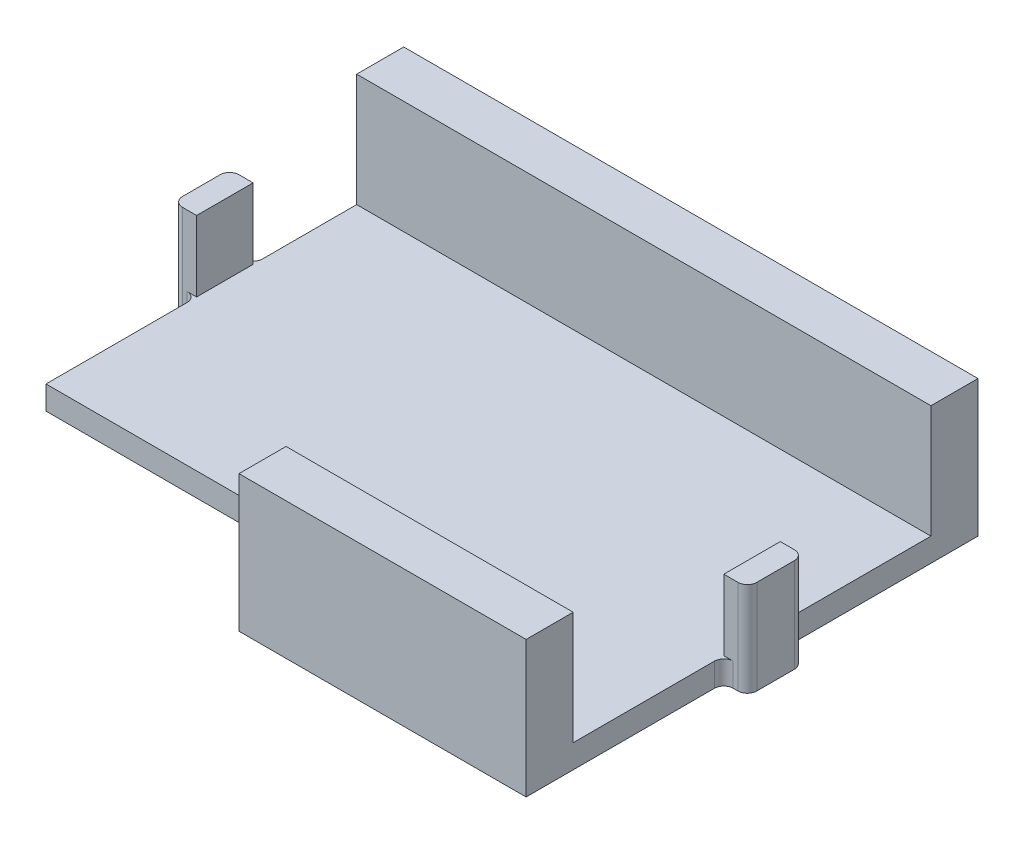
from build123d import *

# Parameters (mm, degrees)
BOSS_EXTRUDE1_DEPTH = 2.5
SKETCH2_W           = 61
SKETCH2_H           = 5
SKETCH2_W_2         = 30.5
BOSS_EXTRUDE2_DEPTH = 12
CUT_EXTRUDE1_DEPTH  = 1
SKETCH5_W           = 2.5
SKETCH5_H           = 6
BOSS_EXTRUDE3_DEPTH = 10
FILLET4_R           = 1


with BuildPart() as part:
    # Sketch1 → Boss-Extrude1 (new body)
    with BuildSketch(Plane(origin=(0, 0, 0), x_dir=(1, 0, 0), z_dir=(0, 1, 0))):
        Polygon((0, 10), (30.5, 10), (30.5, 0), (61, 0), (61, 48), (0, 48), align=None)
    extrude(amount=BOSS_EXTRUDE1_DEPTH)

    # Sketch2 → Boss-Extrude2 (add)
    with BuildSketch(Plane(origin=(0, 2.5, 0), x_dir=(1, 0, 0), z_dir=(0, 1, 0))):
        with Locations((30.5, 45.5)):
            Rectangle(SKETCH2_W, SKETCH2_H)
        with Locations((45.75, 2.5)):
            Rectangle(SKETCH2_W_2, SKETCH2_H)
    extrude(amount=BOSS_EXTRUDE2_DEPTH)

    # Sketch3 → Cut-Extrude1 (cut)
    with BuildSketch(Plane.XZ):
        with BuildLine():
            Line((38.1875, -27), (39.6, -27))
            Line((39.6, -27), (39.6, -24.8421875))
            add(Edge.make_bspline(
                [(39.6, -24.8421875), (39.602615405, -24.769084793), (39.607534256, -24.631598895), (39.645917421, -24.438286667), (39.71249642, -24.273057168), (39.80650625, -24.137413973), (39.920250057, -24.03091493), (40.049992557, -23.954750809), (40.194402262, -23.908778619), (40.294972194, -23.902988305), (40.346875, -23.9)],
                knots=[0, 0, 0, 0, 0.000219202, 0.000412257, 0.000588099, 0.000749771, 0.000903445, 0.001051907, 0.001197689, 0.001353164, 0.001353164, 0.001353164, 0.001353164], degree=3))
            add(Edge.make_bspline(
                [(40.346875, -23.9), (40.400811886, -23.903069829), (40.505370426, -23.9090208), (40.654616604, -23.95331831), (40.785818729, -24.030620386), (40.898267418, -24.137525593), (40.989912112, -24.272508914), (41.055867465, -24.436263579), (41.094160201, -24.627408298), (41.097981983, -24.763877569), (41.1, -24.8359375)],
                knots=[0, 0, 0, 0, 0.000161694, 0.00031345, 0.000461912, 0.000614446, 0.000775232, 0.000947589, 0.001140645, 0.001356632, 0.001356632, 0.001356632, 0.001356632], degree=3))
            Line((41.1, -24.8359375), (41.1, -30.7484375))
            add(Edge.make_bspline(
                [(41.1, -30.7484375), (41.099564666, -30.789608087), (41.098725346, -30.868984644), (41.087679787, -30.98393408), (41.069116088, -31.089395785), (41.044395541, -31.186415943), (41.011489006, -31.273687026), (40.972763577, -31.35292309), (40.925545184, -31.42249894), (40.851306001, -31.502978541), (40.733925262, -31.585343097), (40.562936526, -31.653276145), (40.358565351, -31.693106891), (40.211651668, -31.697592735), (40.1328125, -31.7)],
                knots=[0, 0, 0, 0, 0.000123477, 0.000238063, 0.000345954, 0.000444491, 0.000537941, 0.000625288, 0.000708497, 0.00078922, 0.000952693, 0.001133464, 0.001337549, 0.001573905, 0.001573905, 0.001573905, 0.001573905], degree=3))
            Line((40.1328125, -31.7), (38.1734375, -31.7))
            add(Edge.make_bspline(
                [(38.1734375, -31.7), (38.103112581, -31.700035372), (37.96658071, -31.700104044), (37.768157568, -31.691054163), (37.58205737, -31.681244136), (37.408685819, -31.664781958), (37.247289379, -31.647623515), (37.099076931, -31.62146964), (36.962560228, -31.594754723), (36.876957605, -31.570836449), (36.8359375, -31.559375)],
                knots=[0, 0, 0, 0, 0.000210943, 0.000409535, 0.000595793, 0.000769933, 0.000931959, 0.001082487, 0.001221304, 0.001349028, 0.001349028, 0.001349028, 0.001349028], degree=3))
            add(Edge.make_bspline(
                [(36.8359375, -31.559375), (36.758174787, -31.535693231), (36.605197894, -31.48910582), (36.390091341, -31.388381046), (36.189773634, -31.269615451), (36.006592335, -31.12861923), (35.842172885, -30.96773624), (35.699559897, -30.788048857), (35.576231309, -30.592456035), (35.474550885, -30.379737692), (35.397163841, -30.150698292), (35.341005355, -29.908428323), (35.305483612, -29.652613392), (35.301855407, -29.477202426), (35.3, -29.3875)],
                knots=[0, 0, 0, 0, 0.000243595, 0.000479206, 0.000710461, 0.000941103, 0.001170924, 0.00139884, 0.001627734, 0.001863257, 0.002104389, 0.002351501, 0.002608498, 0.002877471, 0.002877471, 0.002877471, 0.002877471], degree=3))
            add(Edge.make_bspline(
                [(35.3, -29.3875), (35.301809825, -29.292586825), (35.30533284, -29.107828413), (35.341011258, -28.839627251), (35.395696925, -28.588344436), (35.476429153, -28.355502686), (35.577363674, -28.139551849), (35.704023887, -27.942951805), (35.851833656, -27.762963601), (36.023207918, -27.601603438), (36.217200455, -27.458365944), (36.433788728, -27.334655233), (36.673512874, -27.232454742), (36.933425896, -27.145634461), (37.216328859, -27.081746386), (37.519917531, -27.032769881), (37.84636014, -27.005079255), (38.071303311, -27.001730061), (38.1875, -27)],
                knots=[0, 0, 0, 0, 0.000284585, 0.000553975, 0.000810225, 0.00105482, 0.001291754, 0.001523642, 0.001754511, 0.001988834, 0.002227902, 0.002476359, 0.002735282, 0.003008523, 0.003297327, 0.003604298, 0.003930513, 0.004279076, 0.004279076, 0.004279076, 0.004279076], degree=3))
        make_face()
        with BuildLine():
            Line((38.5609375, -30.5), (39.6, -30.5))
            Line((39.6, -30.5), (39.6, -28.2))
            Line((39.6, -28.2), (38.5609375, -28.2))
            add(Edge.make_bspline(
                [(38.5609375, -28.2), (38.473925807, -28.201685184), (38.306945409, -28.204919149), (38.067107498, -28.224188963), (37.84970512, -28.25980799), (37.65410835, -28.309033712), (37.480223381, -28.3740791), (37.327553707, -28.457520614), (37.19637362, -28.559225985), (37.088067853, -28.680511212), (37.001621577, -28.82004504), (36.943027083, -28.981175779), (36.906595982, -29.161394296), (36.902263617, -29.288352923), (36.9, -29.3546875)],
                knots=[0, 0, 0, 0, 0.000261054, 0.000500978, 0.000721119, 0.000921217, 0.001105194, 0.001276535, 0.001441259, 0.001600603, 0.001761927, 0.00193054, 0.002112254, 0.002311084, 0.002311084, 0.002311084, 0.002311084], degree=3))
            add(Edge.make_bspline(
                [(36.9, -29.3546875), (36.903364233, -29.434236925), (36.909848384, -29.587558781), (36.966431543, -29.805808259), (37.057238421, -30.003435042), (37.149400887, -30.111694511), (37.1953125, -30.165625)],
                knots=[0, 0, 0, 0, 0.000238239, 0.000459177, 0.000672331, 0.000883921, 0.000883921, 0.000883921, 0.000883921], degree=3))
            add(Edge.make_bspline(
                [(37.1953125, -30.165625), (37.225735979, -30.19276864), (37.290030891, -30.250132162), (37.408815453, -30.317269388), (37.54843091, -30.373136489), (37.708729079, -30.419369207), (37.890973375, -30.456831222), (38.095231339, -30.482248599), (38.321103054, -30.498011146), (38.47861699, -30.499317348), (38.5609375, -30.5)],
                knots=[0, 0, 0, 0, 0.000122035, 0.000257901, 0.000406462, 0.000572587, 0.000757676, 0.00096408, 0.001189621, 0.001436541, 0.001436541, 0.001436541, 0.001436541], degree=3))
        make_face(mode=Mode.SUBTRACT)
        with BuildLine():
            add(Edge.make_bspline(
                [(27.3953125, -26.4515625), (27.397434395, -26.389433762), (27.401815522, -26.261155035), (27.438676119, -26.066027702), (27.49508646, -25.862986158), (27.575462199, -25.654509555), (27.676999221, -25.441216064), (27.810927351, -25.232591398), (27.966003207, -25.022936194), (28.147847897, -24.817903952), (28.356369794, -24.622072842), (28.59422462, -24.445271264), (28.857924229, -24.287111598), (29.147826391, -24.149406865), (29.463719448, -24.035657986), (29.807343765, -23.957565551), (30.175103983, -23.907880656), (30.428998104, -23.902673778), (30.559375, -23.9)],
                knots=[0, 0, 0, 0, 0.000186259, 0.000384573, 0.000593838, 0.000817864, 0.001054066, 0.001301178, 0.001560242, 0.001835849, 0.002122179, 0.002416867, 0.002723153, 0.003043252, 0.003378327, 0.003728149, 0.004098518, 0.004489455, 0.004489455, 0.004489455, 0.004489455], degree=3))
            add(Edge.make_bspline(
                [(30.559375, -23.9), (30.658907566, -23.900818023), (30.853542013, -23.902417653), (31.138651795, -23.926098172), (31.410314201, -23.958436313), (31.668437928, -24.009492265), (31.91383369, -24.073164845), (32.148411511, -24.150895125), (32.370734316, -24.246731815), (32.582544659, -24.358413872), (32.786445998, -24.485270243), (32.979262764, -24.63299341), (33.165986579, -24.797359597), (33.279688705, -24.920302684), (33.3375, -24.9828125)],
                knots=[0, 0, 0, 0, 0.000298503, 0.000583718, 0.000857758, 0.00111884, 0.001372379, 0.001617951, 0.001859431, 0.002097763, 0.002335766, 0.002578894, 0.002825695, 0.003080976, 0.003080976, 0.003080976, 0.003080976], degree=3))
            add(Edge.make_bspline(
                [(33.3375, -24.9828125), (33.387732238, -25.045256239), (33.488415919, -25.170416213), (33.62664404, -25.369767653), (33.751305978, -25.581322722), (33.864560031, -25.802969389), (33.96889525, -26.032668078), (34.057049874, -26.271575372), (34.132994172, -26.518144216), (34.192776415, -26.77262262), (34.24219802, -27.034713776), (34.275782698, -27.304499098), (34.296930981, -27.58246952), (34.298966516, -27.770273188), (34.3, -27.865625)],
                knots=[0, 0, 0, 0, 0.000240371, 0.000481791, 0.000726984, 0.000976461, 0.001228237, 0.001483351, 0.001739872, 0.002001749, 0.002267144, 0.002539633, 0.002816941, 0.003102946, 0.003102946, 0.003102946, 0.003102946], degree=3))
            add(Edge.make_bspline(
                [(34.3, -27.865625), (34.296928776, -28.018393355), (34.290935568, -28.316506669), (34.237641938, -28.750738581), (34.155057159, -29.161415944), (34.034040456, -29.546173325), (33.88237364, -29.905712762), (33.700578841, -30.238948675), (33.488694914, -30.545554745), (33.247756976, -30.823816255), (32.981430376, -31.072732337), (32.692976857, -31.291699142), (32.381102483, -31.475879662), (32.05203128, -31.631243154), (31.706067235, -31.751129862), (31.347662006, -31.837256518), (30.978149733, -31.890278039), (30.727778247, -31.896741619), (30.6015625, -31.9)],
                knots=[0, 0, 0, 0, 0.000458135, 0.000894008, 0.001310458, 0.001713222, 0.002101811, 0.002479406, 0.002849985, 0.003217754, 0.003581454, 0.003941769, 0.004301917, 0.004666091, 0.005031762, 0.005398231, 0.005770569, 0.006149084, 0.006149084, 0.006149084, 0.006149084], degree=3))
            add(Edge.make_bspline(
                [(30.6015625, -31.9), (30.524441789, -31.898742886), (30.37209357, -31.896259519), (30.146868459, -31.878236684), (29.927344507, -31.851668844), (29.715127789, -31.807665956), (29.508340081, -31.757818429), (29.309085734, -31.692186568), (29.115241089, -31.618473757), (28.929616127, -31.530224099), (28.752874019, -31.433744499), (28.58541226, -31.332208627), (28.428296632, -31.226138053), (28.282641161, -31.112876748), (28.146773866, -30.995181346), (28.023157809, -30.870413965), (27.907947472, -30.742735672), (27.806217947, -30.608384363), (27.713796985, -30.473947596), (27.635979163, -30.338426372), (27.567750702, -30.206018755), (27.513878594, -30.074398002), (27.468222606, -29.946218289), (27.43961528, -29.818620064), (27.419205469, -29.693361827), (27.416809536, -29.609975649), (27.415625, -29.56875)],
                knots=[0, 0, 0, 0, 0.000231334, 0.00045699, 0.000677541, 0.000894188, 0.001106785, 0.001315308, 0.001523067, 0.001728564, 0.001931328, 0.002126947, 0.002315899, 0.002499671, 0.002680172, 0.002854739, 0.00302628, 0.003195665, 0.003359913, 0.003515349, 0.003664189, 0.003806376, 0.003941765, 0.004071763, 0.004198161, 0.004321757, 0.004321757, 0.004321757, 0.004321757], degree=3))
            add(Edge.make_bspline(
                [(27.415625, -29.56875), (27.418216573, -29.525307673), (27.423326947, -29.439642884), (27.458565709, -29.31483296), (27.519738515, -29.199264042), (27.601639003, -29.094485493), (27.700373583, -29.005106438), (27.812919531, -28.94061161), (27.935086452, -28.898330021), (28.020481916, -28.894263038), (28.0640625, -28.8921875)],
                knots=[0, 0, 0, 0, 0.000130289, 0.000256919, 0.00038551, 0.00052022, 0.000654131, 0.000782237, 0.000907247, 0.001037535, 0.001037535, 0.001037535, 0.001037535], degree=3))
            add(Edge.make_bspline(
                [(28.0640625, -28.8921875), (28.11106611, -28.893946378), (28.200179439, -28.897281004), (28.324887939, -28.922962447), (28.43172227, -28.968196434), (28.520138472, -29.036800167), (28.598928401, -29.127534222), (28.680965048, -29.239061767), (28.76480885, -29.378834016), (28.82022041, -29.481020091), (28.85, -29.5359375)],
                knots=[0, 0, 0, 0, 0.000140937, 0.0002672, 0.000379841, 0.000485781, 0.000599715, 0.000739408, 0.000900732, 0.00108816, 0.00108816, 0.00108816, 0.00108816], degree=3))
            add(Edge.make_bspline(
                [(28.85, -29.5359375), (28.901211449, -29.62825275), (29.000008605, -29.806347382), (29.17412368, -30.045485691), (29.362747316, -30.247263649), (29.564423253, -30.415768884), (29.788184683, -30.545230891), (30.034861588, -30.636014618), (30.305541211, -30.689354721), (30.49350599, -30.696373491), (30.590625, -30.7)],
                knots=[0, 0, 0, 0, 0.000316494, 0.00061058, 0.000884727, 0.001143409, 0.001396133, 0.001656185, 0.001928603, 0.002219832, 0.002219832, 0.002219832, 0.002219832], degree=3))
            add(Edge.make_bspline(
                [(30.590625, -30.7), (30.668904848, -30.698261598), (30.82268842, -30.694846445), (31.04630224, -30.65733031), (31.25832523, -30.59983937), (31.457865159, -30.518199368), (31.645312593, -30.412783723), (31.819870085, -30.282917498), (31.983147995, -30.131118747), (32.131501037, -29.954683731), (32.265655206, -29.757941294), (32.383149221, -29.541347392), (32.482331498, -29.304856673), (32.560445287, -29.048469195), (32.623417413, -28.772809997), (32.668074561, -28.477773945), (32.694558587, -28.162986086), (32.69815336, -27.946927256), (32.7, -27.8359375)],
                knots=[0, 0, 0, 0, 0.00023463, 0.000460939, 0.000678149, 0.000892576, 0.001105959, 0.00132159, 0.0015438, 0.001773275, 0.002011637, 0.002257049, 0.002511257, 0.002779611, 0.003060101, 0.003358869, 0.003674053, 0.004006998, 0.004006998, 0.004006998, 0.004006998], degree=3))
            add(Edge.make_bspline(
                [(32.7, -27.8359375), (32.698833253, -27.760931136), (32.69655527, -27.614486963), (32.686542363, -27.399076416), (32.665280534, -27.193891054), (32.640015517, -26.997520446), (32.603466249, -26.811507385), (32.56041258, -26.635005369), (32.508120395, -26.468274026), (32.449927797, -26.310651199), (32.381075769, -26.16367205), (32.310818082, -26.023934919), (32.230340137, -25.89514944), (32.143127881, -25.776982149), (32.04986706, -25.667643547), (31.950588506, -25.567776514), (31.843489711, -25.478402803), (31.693281427, -25.371883839), (31.489732233, -25.262067222), (31.225379638, -25.167679785), (30.94102803, -25.109994376), (30.744546838, -25.103388752), (30.64375, -25.1)],
                knots=[0, 0, 0, 0, 0.000225049, 0.000439391, 0.000646638, 0.000843749, 0.001033127, 0.00121503, 0.001388495, 0.001557108, 0.001718621, 0.001875159, 0.002026044, 0.002173549, 0.002315401, 0.002456823, 0.002595463, 0.002733327, 0.003008793, 0.00328606, 0.00357288, 0.003875025, 0.003875025, 0.003875025, 0.003875025], degree=3))
            add(Edge.make_bspline(
                [(30.64375, -25.1), (30.588489942, -25.100593687), (30.479768196, -25.10176174), (30.320612286, -25.120042027), (30.167791943, -25.146807154), (30.020831754, -25.181431319), (29.881027725, -25.230719935), (29.748093101, -25.290387087), (29.620719037, -25.359159796), (29.500104525, -25.438731593), (29.387498939, -25.530229656), (29.281140777, -25.630630295), (29.180145082, -25.7394719), (29.090208217, -25.861250123), (29.005084319, -25.991365687), (28.927399639, -26.131868605), (28.856565342, -26.282083188), (28.816988353, -26.387202497), (28.796875, -26.440625)],
                knots=[0, 0, 0, 0, 0.000165691, 0.00032599, 0.000479863, 0.000631071, 0.000778327, 0.000923808, 0.001067838, 0.001212147, 0.001356609, 0.001502516, 0.001650715, 0.001801341, 0.00195606, 0.002116929, 0.002282591, 0.002453783, 0.002453783, 0.002453783, 0.002453783], degree=3))
            add(Edge.make_bspline(
                [(28.796875, -26.440625), (28.779923737, -26.49039154), (28.747176989, -26.586531418), (28.687691881, -26.720620223), (28.623103662, -26.841257823), (28.553013155, -26.948413623), (28.467251361, -27.040271656), (28.354687836, -27.10142068), (28.221471962, -27.137410906), (28.125771742, -27.141552673), (28.075, -27.14375)],
                knots=[0, 0, 0, 0, 0.000157658, 0.000304566, 0.000439494, 0.000567771, 0.000688206, 0.000812048, 0.000946623, 0.0010987, 0.0010987, 0.0010987, 0.0010987], degree=3))
            add(Edge.make_bspline(
                [(28.075, -27.14375), (28.029903738, -27.141508843), (27.941198654, -27.137100449), (27.814095489, -27.097167016), (27.695459856, -27.036124439), (27.592900486, -26.94770771), (27.503846104, -26.84423332), (27.441625361, -26.723661053), (27.401582242, -26.591574897), (27.397448484, -26.499262112), (27.3953125, -26.4515625)],
                knots=[0, 0, 0, 0, 0.000134955, 0.000265459, 0.000396159, 0.000532599, 0.000669038, 0.000803231, 0.000936731, 0.001079467, 0.001079467, 0.001079467, 0.001079467], degree=3))
        make_face()
        with BuildLine():
            Line((22.609375, -24), (24.95625, -24))
            add(Edge.make_bspline(
                [(24.95625, -24), (24.997415558, -24.00044181), (25.076263915, -24.001288052), (25.190254306, -24.012085866), (25.294261467, -24.031717368), (25.390986138, -24.053200458), (25.477078179, -24.087562104), (25.555956611, -24.125038751), (25.62369368, -24.17349785), (25.705027455, -24.244824252), (25.786617851, -24.360816671), (25.853445579, -24.530393885), (25.892921937, -24.732596084), (25.897538073, -24.878457572), (25.9, -24.95625)],
                knots=[0, 0, 0, 0, 0.000123477, 0.000236507, 0.000342861, 0.000441013, 0.000533001, 0.000620348, 0.000702271, 0.000781943, 0.00094415, 0.001121437, 0.001325521, 0.001558758, 0.001558758, 0.001558758, 0.001558758], degree=3))
            Line((25.9, -24.95625), (25.9, -30.74375))
            add(Edge.make_bspline(
                [(25.9, -30.74375), (25.897849137, -30.823174119), (25.893850401, -30.970833982), (25.851264008, -31.174607226), (25.784726551, -31.345849509), (25.682049495, -31.481443137), (25.547883107, -31.584300205), (25.37896778, -31.651640477), (25.178606033, -31.693462879), (25.033573246, -31.697726747), (24.95625, -31.7)],
                knots=[0, 0, 0, 0, 0.000237916, 0.000442317, 0.000621644, 0.000784459, 0.000946033, 0.001122478, 0.00132535, 0.001557027, 0.001557027, 0.001557027, 0.001557027], degree=3))
            Line((24.95625, -31.7), (22.46875, -31.7))
            add(Edge.make_bspline(
                [(22.46875, -31.7), (22.380195084, -31.699016417), (22.209243581, -31.697117653), (21.961598382, -31.684980581), (21.732143127, -31.663431667), (21.51900852, -31.632807584), (21.320018105, -31.589552454), (21.133341895, -31.529839763), (20.956539538, -31.455218626), (20.846817504, -31.392276194), (20.7921875, -31.3609375)],
                knots=[0, 0, 0, 0, 0.000265666, 0.000512858, 0.000743584, 0.000956824, 0.001158502, 0.001353689, 0.001544083, 0.001732881, 0.001732881, 0.001732881, 0.001732881], degree=3))
            add(Edge.make_bspline(
                [(20.7921875, -31.3609375), (20.746859819, -31.332552516), (20.65620876, -31.275785243), (20.530170425, -31.176793863), (20.411485761, -31.067709117), (20.301206611, -30.948440861), (20.201696205, -30.819051469), (20.113725938, -30.682710597), (20.038552778, -30.539936674), (19.9755159, -30.39122794), (19.927319562, -30.236725481), (19.893400873, -30.077676468), (19.86982407, -29.914766049), (19.868072242, -29.804251604), (19.8671875, -29.7484375)],
                knots=[0, 0, 0, 0, 0.000160352, 0.00032069, 0.000479927, 0.000643579, 0.000807344, 0.000969008, 0.001129763, 0.001290822, 0.001452916, 0.001614429, 0.001778395, 0.001945699, 0.001945699, 0.001945699, 0.001945699], degree=3))
            add(Edge.make_bspline(
                [(19.8671875, -29.7484375), (19.870692334, -29.654400526), (19.877531182, -29.470909822), (19.933683369, -29.205969805), (20.024066425, -28.960027801), (20.154910751, -28.735520326), (20.321165278, -28.529771878), (20.525259912, -28.345168119), (20.764690162, -28.179226249), (20.943500543, -28.090948264), (21.0359375, -28.0453125)],
                knots=[0, 0, 0, 0, 0.000281874, 0.00055001, 0.000808598, 0.00106481, 0.001325916, 0.001599086, 0.001887742, 0.002196663, 0.002196663, 0.002196663, 0.002196663], degree=3))
            add(Edge.make_bspline(
                [(21.0359375, -28.0453125), (20.973698003, -28.02467476), (20.852230585, -27.984397878), (20.67828039, -27.913252976), (20.515311339, -27.837497473), (20.364676165, -27.753142363), (20.227017994, -27.660166577), (20.099479567, -27.562302095), (19.985422759, -27.455642433), (19.882821782, -27.34231557), (19.792280825, -27.222104467), (19.713097522, -27.094805268), (19.648309964, -26.95964993), (19.591912181, -26.818800434), (19.553102419, -26.668797324), (19.520366123, -26.513198889), (19.504051782, -26.349824039), (19.501365307, -26.239089474), (19.5, -26.1828125)],
                knots=[0, 0, 0, 0, 0.000196664, 0.000383812, 0.000563445, 0.000735547, 0.000901091, 0.001061429, 0.001217311, 0.001368873, 0.001519499, 0.001668232, 0.001817776, 0.00196866, 0.002122556, 0.002281901, 0.002445307, 0.002614173, 0.002614173, 0.002614173, 0.002614173], degree=3))
            add(Edge.make_bspline(
                [(19.5, -26.1828125), (19.503461017, -26.078793647), (19.510295392, -25.873390428), (19.577916521, -25.574954709), (19.680478222, -25.290689567), (19.828282828, -25.027648393), (20.01054828, -24.788969357), (20.223389643, -24.580143173), (20.466711789, -24.404811205), (20.647447054, -24.318666901), (20.7390625, -24.275)],
                knots=[0, 0, 0, 0, 0.0003116, 0.000615309, 0.000913402, 0.001215563, 0.001516514, 0.001811529, 0.002107234, 0.002411219, 0.002411219, 0.002411219, 0.002411219], degree=3))
            add(Edge.make_bspline(
                [(20.7390625, -24.275), (20.799670964, -24.250654322), (20.923446966, -24.200935019), (21.119452541, -24.142151292), (21.327917118, -24.095542104), (21.550380522, -24.060367094), (21.788509127, -24.031603193), (22.045648513, -24.01451212), (22.3212055, -24.000714391), (22.511438019, -24.000242792), (22.609375, -24)],
                knots=[0, 0, 0, 0, 0.000195868, 0.000400006, 0.00061304, 0.000836264, 0.001075423, 0.001332359, 0.001609203, 0.00190297, 0.00190297, 0.00190297, 0.00190297], degree=3))
        make_face()
        with BuildLine():
            Line((22.7546875, -27.4), (24.4, -27.4))
            Line((24.4, -27.4), (24.4, -25.2))
            Line((24.4, -25.2), (22.7015625, -25.2))
            add(Edge.make_bspline(
                [(22.7015625, -25.2), (22.636960258, -25.200986697), (22.511797831, -25.202898354), (22.330224186, -25.215098838), (22.161051944, -25.236506353), (22.004068057, -25.268094391), (21.859328646, -25.306612649), (21.726069456, -25.352570319), (21.60797199, -25.411598943), (21.499334317, -25.474753655), (21.405751026, -25.550623204), (21.323727607, -25.633772569), (21.253278307, -25.725586969), (21.198095328, -25.827322133), (21.152893651, -25.93708658), (21.122634393, -26.055966699), (21.103312621, -26.183222172), (21.101122499, -26.270759598), (21.1, -26.315625)],
                knots=[0, 0, 0, 0, 0.000193807, 0.000375487, 0.000545649, 0.000704993, 0.000855465, 0.000994834, 0.001126909, 0.001250978, 0.001371037, 0.001487052, 0.001600803, 0.001716902, 0.001833254, 0.001956047, 0.002083991, 0.002218511, 0.002218511, 0.002218511, 0.002218511], degree=3))
            add(Edge.make_bspline(
                [(21.1, -26.315625), (21.100918247, -26.361559449), (21.102701925, -26.45078631), (21.12455026, -26.579321889), (21.154243394, -26.699068274), (21.200228922, -26.808598692), (21.26045565, -26.907048509), (21.331157689, -26.997968126), (21.41621538, -27.077645787), (21.514602046, -27.147444096), (21.626628063, -27.205245528), (21.748964547, -27.259961896), (21.886078313, -27.302656472), (22.035457789, -27.338174392), (22.197245874, -27.36607614), (22.371403958, -27.386717839), (22.558741209, -27.396598962), (22.688012701, -27.398842726), (22.7546875, -27.4)],
                knots=[0, 0, 0, 0, 0.000137642, 0.000267367, 0.00039016, 0.000507108, 0.000622066, 0.000735538, 0.000851595, 0.000970386, 0.001096214, 0.001229164, 0.001371968, 0.001526213, 0.00168959, 0.001864213, 0.002052031, 0.002252086, 0.002252086, 0.002252086, 0.002252086], degree=3))
        make_face(mode=Mode.SUBTRACT)
        with BuildLine():
            Line((24.4, -30.5), (24.4, -28.5))
            Line((24.4, -28.5), (22.9515625, -28.5))
            add(Edge.make_bspline(
                [(22.9515625, -28.5), (22.858796315, -28.500722054), (22.683904339, -28.502083342), (22.438614122, -28.524429591), (22.226048411, -28.557188245), (22.043688346, -28.604703837), (21.885532563, -28.672434831), (21.751561104, -28.76811269), (21.635091924, -28.887969958), (21.576861926, -28.983577247), (21.546875, -29.0328125)],
                knots=[0, 0, 0, 0, 0.000278195, 0.000524481, 0.000738201, 0.000922795, 0.001088582, 0.001251149, 0.001413597, 0.001586074, 0.001586074, 0.001586074, 0.001586074], degree=3))
            add(Edge.make_bspline(
                [(21.546875, -29.0328125), (21.525855906, -29.07027428), (21.483996925, -29.144878444), (21.442815471, -29.267652577), (21.414358889, -29.396077388), (21.412088661, -29.484733047), (21.4109375, -29.5296875)],
                knots=[0, 0, 0, 0, 0.000128591, 0.000256086, 0.000386935, 0.000521537, 0.000521537, 0.000521537, 0.000521537], degree=3))
            add(Edge.make_bspline(
                [(21.4109375, -29.5296875), (21.411837646, -29.57665573), (21.413557483, -29.666394103), (21.434794111, -29.794758858), (21.466882615, -29.911008904), (21.512553098, -30.016103823), (21.571737287, -30.108862221), (21.645633752, -30.18873812), (21.732142536, -30.256308628), (21.832864846, -30.311294452), (21.946751108, -30.35589558), (22.073274986, -30.394531848), (22.213647079, -30.427629539), (22.367803007, -30.452816228), (22.535414186, -30.475892536), (22.716536468, -30.488203364), (22.911339088, -30.498589694), (23.045815945, -30.499518067), (23.115625, -30.5)],
                knots=[0, 0, 0, 0, 0.000140764, 0.000268946, 0.000389137, 0.000501778, 0.000611431, 0.000717589, 0.000826674, 0.000939282, 0.001060565, 0.001193018, 0.0013359, 0.001492851, 0.001661464, 0.001843258, 0.002037235, 0.002246633, 0.002246633, 0.002246633, 0.002246633], degree=3))
            Line((23.115625, -30.5), (24.4, -30.5))
        make_face(mode=Mode.SUBTRACT)
    extrude(amount=-CUT_EXTRUDE1_DEPTH, mode=Mode.SUBTRACT)

    # Sketch5 → Boss-Extrude3 (add)
    with BuildSketch(Plane.XZ):
        with Locations((-1.25, -29)):
            Rectangle(SKETCH5_W, SKETCH5_H)
        with Locations((62.25, -24)):
            Rectangle(SKETCH5_W, SKETCH5_H)
    extrude(amount=-BOSS_EXTRUDE3_DEPTH)

    # Fillet4
    fillet4_edges = [part.edges().sort_by_distance(p)[0] for p in [
        (0, 1.25, -26),
        (0, 1.25, -32),
        (-2.5, 5, -32),
        (-2.5, 5, -26),
        (61, 1.25, -27),
        (61, 1.25, -21),
        (63.5, 5, -21),
        (63.5, 5, -27),
    ]]
    fillet(fillet4_edges, radius=FILLET4_R)


solid = part.part
